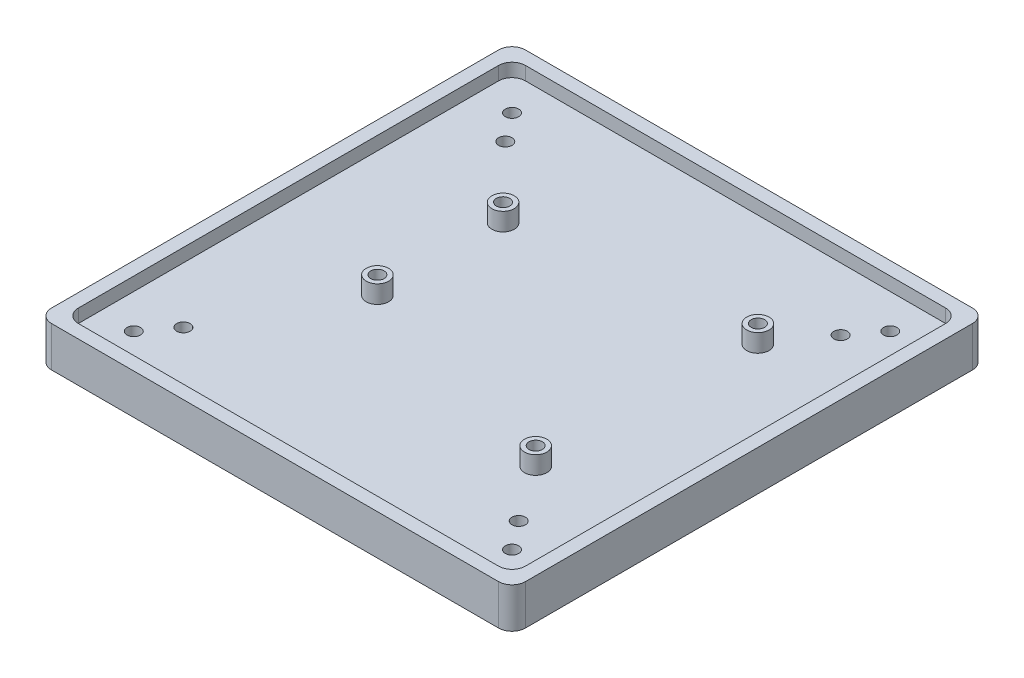
from build123d import *

# Parameters (mm, degrees)
SKETCH1_W                = 145.96883028
SKETCH1_H                = 100
SKETCH1_R                = 1.5
BOSS_EXTRUDE1_DEPTH      = 6
SKETCH4_R                = 2.5
SKETCH4_R_2              = 1.5
BOSS_EXTRUDE4_DEPTH      = 4
SKETCH5_W                = 45.97
SKETCH5_H                = 134.813317764
CUT_EXTRUDE3_DEPTH       = 10
SKETCH7_W                = 105.99883028
SKETCH7_H                = 106
SKETCH7_W_2              = 99.99883028
SKETCH7_H_2              = 100
BOSS_EXTRUDE5_DEPTH      = 3
BOSS_EXTRUDE5_DEPTH_BACK = 6
FILLET1_R                = 3
SKETCH8_R                = 1.5
CUT_EXTRUDE4_DEPTH       = 10
SKETCH9_R                = 1.5
CUT_EXTRUDE5_DEPTH       = 94.411087908
SKETCH10_R               = 3
CUT_EXTRUDE6_DEPTH       = 3


with BuildPart() as part:
    # Sketch1 → Boss-Extrude1 (new body)
    with BuildSketch(Plane(origin=(0, 0, 0), x_dir=(1, 0, 0), z_dir=(0, 1, 0))):
        with Locations((0, 1)):
            Rectangle(SKETCH1_W, SKETCH1_H)
        with Locations(Location((52.98441514, 26, 0), (0, 0, 270))):
            Circle(SKETCH1_R, mode=Mode.SUBTRACT)
        with Locations(Location((0.98441514, 21, 0), (0, 0, 270))):
            Circle(SKETCH1_R, mode=Mode.SUBTRACT)
        with Locations(Location((0.98441514, -7.1, 0), (0, 0, 270))):
            Circle(SKETCH1_R, mode=Mode.SUBTRACT)
        with Locations(Location((51.78441514, -22.5, 0), (0, 0, 270))):
            Circle(SKETCH1_R, mode=Mode.SUBTRACT)
        with Locations(Location((-66.5, 14.15, 0), (0, 0, 270))):
            Circle(SKETCH1_R, mode=Mode.SUBTRACT)
        with Locations(Location((-35.9, 14.15, 0), (0, 0, 270))):
            Circle(SKETCH1_R, mode=Mode.SUBTRACT)
        with Locations(Location((-66.5, -12.15, 0), (0, 0, 270))):
            Circle(SKETCH1_R, mode=Mode.SUBTRACT)
        with Locations(Location((-36.1, -12.15, 0), (0, 0, 270))):
            Circle(SKETCH1_R, mode=Mode.SUBTRACT)
        with Locations(Location((-65.48441514, 38.5, 0), (0, 0, 270))):
            Circle(SKETCH1_R, mode=Mode.SUBTRACT)
        with Locations(Location((-65.48441514, -36.5, 0), (0, 0, 270))):
            Circle(SKETCH1_R, mode=Mode.SUBTRACT)
    extrude(amount=BOSS_EXTRUDE1_DEPTH)

    # Sketch4 → Boss-Extrude4 (add)
    with BuildSketch(Plane(origin=(0, 6, 0), x_dir=(1, 0, 0), z_dir=(0, 1, 0))):
        with Locations(Location((51.78441514, -22.5, 0), (0, 0, 270))):
            Circle(SKETCH4_R)
        with Locations(Location((51.78441514, -22.5, 0), (0, 0, 270))):
            Circle(SKETCH4_R_2, mode=Mode.SUBTRACT)
        with Locations(Location((52.98441514, 26, 0), (0, 0, 270))):
            Circle(SKETCH4_R)
        with Locations(Location((52.98441514, 26, 0), (0, 0, 270))):
            Circle(SKETCH4_R_2, mode=Mode.SUBTRACT)
        with Locations(Location((0.98441514, -7.1, 0), (0, 0, 270))):
            Circle(SKETCH4_R)
        with Locations(Location((0.98441514, -7.1, 0), (0, 0, 270))):
            Circle(SKETCH4_R_2, mode=Mode.SUBTRACT)
        with Locations(Location((0.98441514, 21, 0), (0, 0, 270))):
            Circle(SKETCH4_R)
        with Locations(Location((0.98441514, 21, 0), (0, 0, 270))):
            Circle(SKETCH4_R_2, mode=Mode.SUBTRACT)
        with Locations(Location((-35.9, 14.15, 0), (0, 0, 270))):
            Circle(SKETCH4_R)
        with Locations(Location((-35.9, 14.15, 0), (0, 0, 270))):
            Circle(SKETCH4_R_2, mode=Mode.SUBTRACT)
        with Locations(Location((-36.1, -12.15, 0), (0, 0, 270))):
            Circle(SKETCH4_R)
        with Locations(Location((-36.1, -12.15, 0), (0, 0, 270))):
            Circle(SKETCH4_R_2, mode=Mode.SUBTRACT)
        with Locations(Location((-66.5, -12.15, 0), (0, 0, 270))):
            Circle(SKETCH4_R)
        with Locations(Location((-66.5, -12.15, 0), (0, 0, 270))):
            Circle(SKETCH4_R_2, mode=Mode.SUBTRACT)
        with Locations(Location((-66.5, 14.15, 0), (0, 0, 270))):
            Circle(SKETCH4_R)
        with Locations(Location((-66.5, 14.15, 0), (0, 0, 270))):
            Circle(SKETCH4_R_2, mode=Mode.SUBTRACT)
    extrude(amount=BOSS_EXTRUDE4_DEPTH)

    # Sketch5 → Cut-Extrude3 (cut)
    with BuildSketch(Plane(origin=(0, 6, 0), x_dir=(1, 0, 0), z_dir=(0, 1, 0))):
        with Locations((-49.99941514, -5.501317008)):
            Rectangle(SKETCH5_W, SKETCH5_H)
    extrude(amount=-CUT_EXTRUDE3_DEPTH, mode=Mode.SUBTRACT)


with BuildPart() as cut_extrude3_kept_piece:
    # of the separate pieces the step leaves, the one the design keeps (cut_extrude3_pieces_kept)
    add(part.part.solids().sort_by_distance((-27.01441514, 0, -51))[0])

    # Sketch7 → Boss-Extrude5 (add, two sides)
    with BuildSketch(Plane(origin=(0, 6, 0), x_dir=(1, 0, 0), z_dir=(0, 1, 0))) as boss_extrude5_sk:
        with Locations((22.985, 1)):
            Rectangle(SKETCH7_W, SKETCH7_H)
        with Locations((22.985, 1)):
            Rectangle(SKETCH7_W_2, SKETCH7_H_2, mode=Mode.SUBTRACT)
    extrude(amount=BOSS_EXTRUDE5_DEPTH)
    extrude(boss_extrude5_sk.sketch, amount=-BOSS_EXTRUDE5_DEPTH_BACK)

    # Fillet1
    fillet1_edges = [cut_extrude3_kept_piece.edges().sort_by_distance(p)[0] for p in [
        (-30.01441514, 4.5, -54),
        (75.98441514, 4.5, -54),
        (75.98441514, 4.5, 52),
        (-30.01441514, 4.5, 52),
        (72.98441514, 7.5, -51),
        (72.98441514, 7.5, 49),
        (-27.01441514, 7.5, 49),
        (-27.01441514, 7.5, -51),
    ]]
    fillet(fillet1_edges, radius=FILLET1_R)

    # Sketch8 → Cut-Extrude4 (cut)
    with BuildSketch(Plane(origin=(0, 6, 0), x_dir=(1, 0, 0), z_dir=(0, 1, 0))):
        with Locations(Location((65.28441514, -41.3, 0), (0, 0, 270))):
            Circle(SKETCH8_R)
        with Locations(Location((65.28441514, 43.3, 0), (0, 0, 270))):
            Circle(SKETCH8_R)
        with Locations(Location((-19.31441514, -41.3, 0), (0, 0, 270))):
            Circle(SKETCH8_R)
        with Locations(Location((-19.31441514, 43.3, 0), (0, 0, 270))):
            Circle(SKETCH8_R)
    extrude(amount=-CUT_EXTRUDE4_DEPTH, mode=Mode.SUBTRACT)

    # Sketch9 → Cut-Extrude5 (cut, through all)
    with BuildSketch(Plane(origin=(0, 6, 0), x_dir=(1, 0, 0), z_dir=(0, 1, 0))):
        with Locations(Location((-14.51441514, -35, 0), (0, 0, 270))):
            Circle(SKETCH9_R)
        with Locations(Location((-14.51441514, 37, 0), (0, 0, 270))):
            Circle(SKETCH9_R)
        with Locations(Location((60.48441514, -35, 0), (0, 0, 270))):
            Circle(SKETCH9_R)
        with Locations(Location((60.48441514, 37, 0), (0, 0, 270))):
            Circle(SKETCH9_R)
    extrude(amount=-CUT_EXTRUDE5_DEPTH, mode=Mode.SUBTRACT)

    # Sketch10 → Cut-Extrude6 (cut)
    with BuildSketch(Plane(origin=(0, 0, 0), x_dir=(-1, 0, 0), z_dir=(0, -1, 0))):
        with Locations(Location((19.31441514, 43.3, 0), (0, 0, 90))):
            Circle(SKETCH10_R)
        with Locations(Location((19.31441514, -41.3, 0), (0, 0, 90))):
            Circle(SKETCH10_R)
        with Locations(Location((-65.28441514, -41.3, 0), (0, 0, 90))):
            Circle(SKETCH10_R)
        with Locations(Location((-65.28441514, 43.3, 0), (0, 0, 90))):
            Circle(SKETCH10_R)
    extrude(amount=-CUT_EXTRUDE6_DEPTH, mode=Mode.SUBTRACT)


solid = cut_extrude3_kept_piece.part
